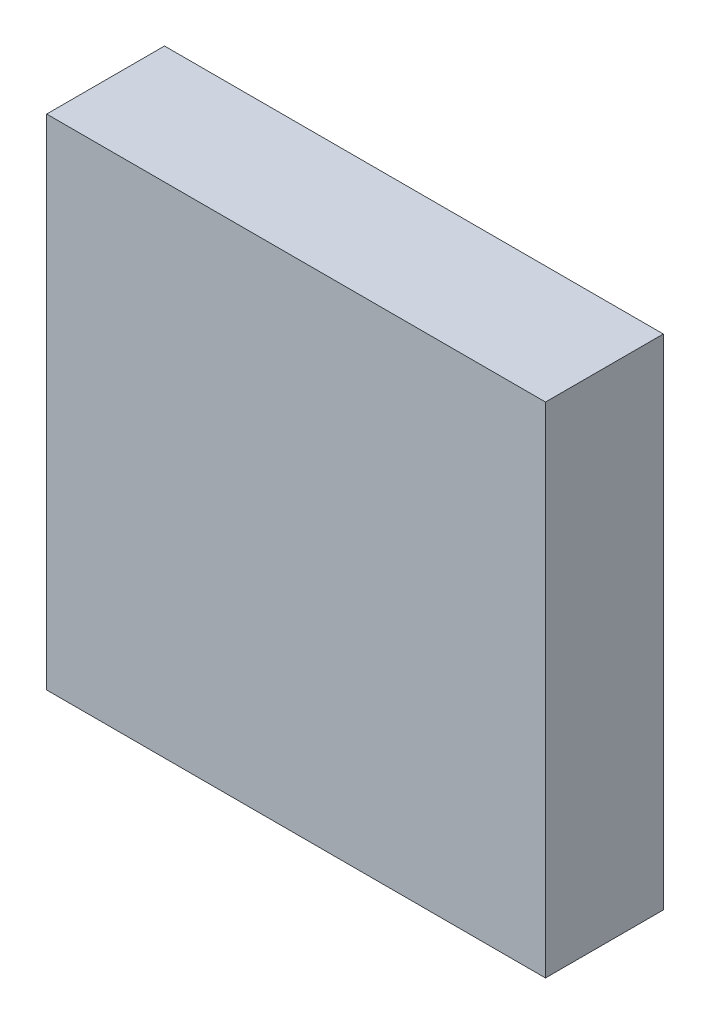
from build123d import *

# Parameters (mm, degrees)
SKETCH1_W           = 25.4
SKETCH1_H           = 25.4
BOSS_EXTRUDE1_DEPTH = 6


with BuildPart() as part:
    # Sketch1 → Boss-Extrude1 (new body)
    with BuildSketch(Plane.XY):
        Rectangle(SKETCH1_W, SKETCH1_H)
    extrude(amount=BOSS_EXTRUDE1_DEPTH)


solid = part.part
